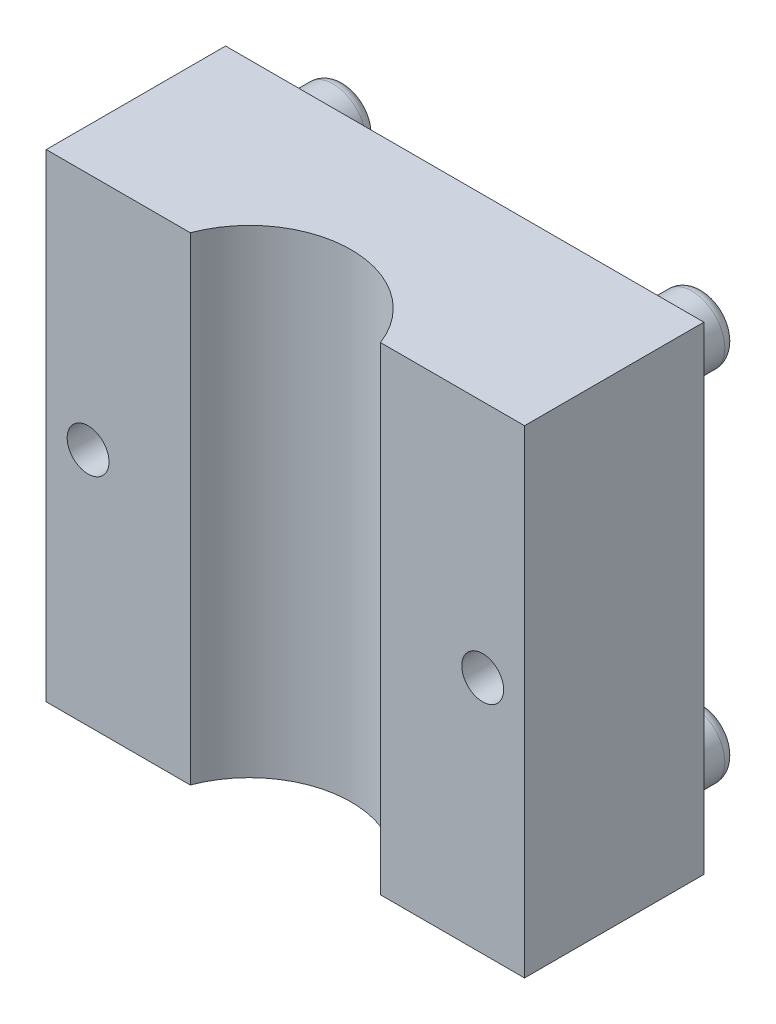
from build123d import *

# Parameters (mm, degrees)
SKETCH1_W           = 40
SKETCH1_H           = 40
BOSS_EXTRUDE1_DEPTH = 15
SKETCH3_R           = 2.75
BOSS_EXTRUDE2_DEPTH = 5
FILLET1_R           = 1
SKETCH4_R           = 12.5
CUT_EXTRUDE1_DEPTH  = 3.5
SKETCH5_R           = 8.5
CUT_EXTRUDE2_DEPTH  = 41
SKETCH6_R           = 3
CUT_EXTRUDE3_DEPTH  = 2
SKETCH7_R           = 1.75
CUT_EXTRUDE4_DEPTH  = 16


with BuildPart() as part:
    # Sketch1 → Boss-Extrude1 (new body)
    with BuildSketch(Plane.XY):
        Rectangle(SKETCH1_W, SKETCH1_H)
    extrude(amount=BOSS_EXTRUDE1_DEPTH)

    # Sketch3 → Boss-Extrude2 (add)
    with BuildSketch(Plane(origin=(0, 0, 0), x_dir=(-1, 0, 0), z_dir=(0, 0, -1))):
        with Locations(Location((-15, 15, 0), (0, 0, 180))):  # turned: the seam where the file's is
            Circle(SKETCH3_R)
        with Locations(Location((15, 15, 0), (0, 0, 180))):  # turned: the seam where the file's is
            Circle(SKETCH3_R)
        with Locations(Location((-15, -15, 0), (0, 0, 180))):  # turned: the seam where the file's is
            Circle(SKETCH3_R)
        with Locations(Location((15, -15, 0), (0, 0, 180))):  # turned: the seam where the file's is
            Circle(SKETCH3_R)
    extrude(amount=BOSS_EXTRUDE2_DEPTH)

    # Fillet1
    fillet1_edges = [part.edges().sort_by_distance(p)[0] for p in [
        (12.25, 15, -5),
        (-17.75, 15, -5),
        (12.25, -15, -5),
        (-17.75, -15, -5),
    ]]
    fillet(fillet1_edges, radius=FILLET1_R)

    # Sketch4 → Cut-Extrude1 (cut)
    with BuildSketch(Plane(origin=(0, 0, 0), x_dir=(-1, 0, 0), z_dir=(0, 0, -1))):
        Circle(SKETCH4_R)
    extrude(amount=-CUT_EXTRUDE1_DEPTH, mode=Mode.SUBTRACT)

    # Sketch5 → Cut-Extrude2 (cut, through all)
    with BuildSketch(Plane(origin=(0, 20, 0), x_dir=(1, 0, 0), z_dir=(0, 1, 0))):
        with Locations((0, -18)):
            Circle(SKETCH5_R)
    extrude(amount=-CUT_EXTRUDE2_DEPTH, mode=Mode.SUBTRACT)

    # Sketch6 → Cut-Extrude3 (cut)
    with BuildSketch(Plane(origin=(0, 0, 0), x_dir=(-1, 0, 0), z_dir=(0, 0, -1))):
        with Locations((-16.5, 0)):
            Circle(SKETCH6_R)
        with Locations((16.5, 0)):
            Circle(SKETCH6_R)
    extrude(amount=-CUT_EXTRUDE3_DEPTH, mode=Mode.SUBTRACT)

    # Sketch7 → Cut-Extrude4 (cut, through all)
    with BuildSketch(Plane(origin=(0, 0, 0), x_dir=(-1, 0, 0), z_dir=(0, 0, -1))):
        with Locations((16.5, 0)):
            Circle(SKETCH7_R)
        with Locations((-16.5, 0)):
            Circle(SKETCH7_R)
    extrude(amount=-CUT_EXTRUDE4_DEPTH, mode=Mode.SUBTRACT)


solid = part.part
